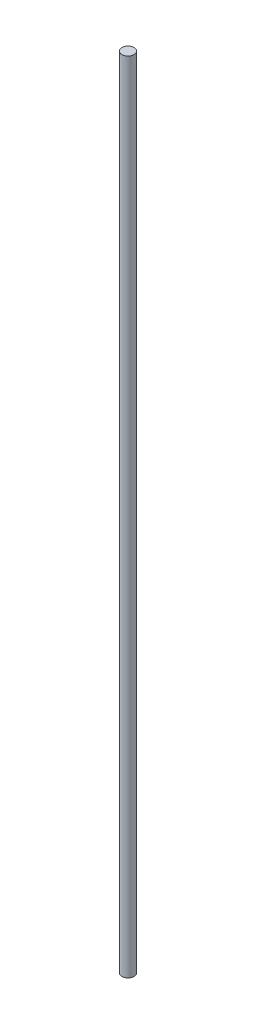
from build123d import *

# Parameters (mm, degrees)
SKETCH1_R           = 2.38125
BOSS_EXTRUDE1_DEPTH = 309.88


with BuildPart() as part:
    # Sketch1 → Boss-Extrude1 (new body)
    with BuildSketch(Plane(origin=(0, 0, 0), x_dir=(1, 0, 0), z_dir=(0, 1, 0))):
        Circle(SKETCH1_R)
    extrude(amount=BOSS_EXTRUDE1_DEPTH)


solid = part.part
